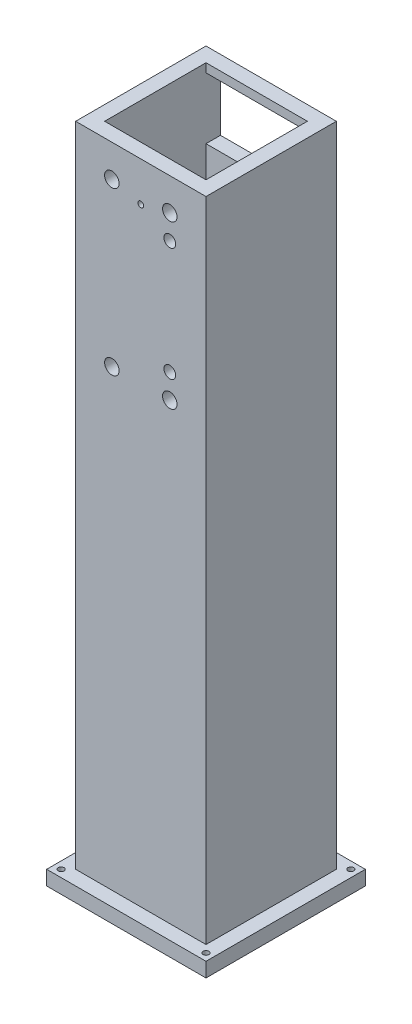
from build123d import *

# Parameters (mm, degrees)
CROQUIS1_W                 = 45
CROQUIS1_H                 = 45
SALIENTE_EXTRUIR1_DEPTH    = 300
CROQUIS4_W                 = 18
CROQUIS4_H                 = 34
CORTAR_EXTRUIR2_DEPTH      = 46
CROQUIS8_W                 = 35
CROQUIS8_H                 = 35
CORTAR_EXTRUIR3_DEPTH      = 301
CROQUIS9_W                 = 35
CROQUIS9_H                 = 21.174410022
CORTAR_EXTRUIR4_DEPTH      = 10
CROQUIS10_R                = 1
CORTAR_EXTRUIR5_DEPTH      = 10
CROQUIS11_W                = 45
CROQUIS11_H                = 26.387879272
CORTAR_EXTRUIR6_DEPTH      = 46
CROQUIS13_W                = 45
CROQUIS13_H                = 50
CORTAR_EXTRUIR7_DEPTH      = 23.5
CORTAR_EXTRUIR7_DEPTH_BACK = 23.5
CROQUIS14_W                = 55
CROQUIS14_H                = 55
SALIENTE_EXTRUIR2_DEPTH    = 5
CROQUIS16_R                = 1
CORTAR_EXTRUIR8_DEPTH      = 1
CORTAR_EXTRUIR8_DEPTH_BACK = 229.612120728
CROQUIS17_R                = 2.5
CROQUIS17_R_2              = 2.03
CORTAR_EXTRUIR9_DEPTH      = 6
CORTAR_EXTRUIR9_DEPTH_BACK = 51


with BuildPart() as part:
    # Croquis1 → Saliente-Extruir1 (new body)
    with BuildSketch(Plane(origin=(0, 0, 0), x_dir=(1, 0, 0), z_dir=(0, 1, 0))):
        Rectangle(CROQUIS1_W, CROQUIS1_H)
    extrude(amount=SALIENTE_EXTRUIR1_DEPTH)

    # Croquis4 → Cortar-Extruir2 (cut, through all)
    with BuildSketch(Plane.ZY.offset(22.5)):
        with Locations((13.5, 17)):
            Rectangle(CROQUIS4_W, CROQUIS4_H)
    extrude(amount=-CORTAR_EXTRUIR2_DEPTH, mode=Mode.SUBTRACT)

    # Croquis8 → Cortar-Extruir3 (cut, through all)
    with BuildSketch(Plane(origin=(0, 300, 0), x_dir=(1, 0, 0), z_dir=(0, 1, 0))):
        Rectangle(CROQUIS8_W, CROQUIS8_H)
    extrude(amount=-CORTAR_EXTRUIR3_DEPTH, mode=Mode.SUBTRACT)

    # Croquis9 → Cortar-Extruir4 (cut)
    with BuildSketch(Plane(origin=(0, 0, -22.5), x_dir=(-1, 0, 0), z_dir=(0, 0, -1))):
        with Locations((0, 260)):
            Rectangle(CROQUIS9_W, CROQUIS9_H)
    extrude(amount=-CORTAR_EXTRUIR4_DEPTH, mode=Mode.SUBTRACT)

    # Croquis10 → Cortar-Extruir5 (cut)
    with BuildSketch(Plane.XY.offset(22.5)):
        with Locations((0, 260)):
            Circle(CROQUIS10_R)
    extrude(amount=-CORTAR_EXTRUIR5_DEPTH, mode=Mode.SUBTRACT)

    # Croquis11 → Cortar-Extruir6 (cut, through all)
    with BuildSketch(Plane.XY.offset(22.5)):
        with Locations((0, 286.806060364)):
            Rectangle(CROQUIS11_W, CROQUIS11_H)
    extrude(amount=-CORTAR_EXTRUIR6_DEPTH, mode=Mode.SUBTRACT)

    # Croquis13 → Cortar-Extruir7 (cut, two sides)
    with BuildSketch(Plane(origin=(0, 0, 0), x_dir=(0, 0, -1), z_dir=(1, 0, 0))) as cortar_extruir7_sk:
        with Locations((0, 25)):
            Rectangle(CROQUIS13_W, CROQUIS13_H)
    extrude(amount=CORTAR_EXTRUIR7_DEPTH, mode=Mode.SUBTRACT)
    extrude(cortar_extruir7_sk.sketch, amount=-CORTAR_EXTRUIR7_DEPTH_BACK, mode=Mode.SUBTRACT)

    # Croquis14 → Saliente-Extruir2 (add)
    with BuildSketch(Plane.XZ.offset(-50)):
        Rectangle(CROQUIS14_W, CROQUIS14_H)
    extrude(amount=SALIENTE_EXTRUIR2_DEPTH)

    # Croquis16 → Cortar-Extruir8 (cut, two sides)
    with BuildSketch(Plane.XZ.offset(-45)) as cortar_extruir8_sk:
        with Locations((25, 25)):
            Circle(CROQUIS16_R)
        with Locations((-25, 25)):
            Circle(CROQUIS16_R)
        with Locations((-25, -25)):
            Circle(CROQUIS16_R)
        with Locations((25, -25)):
            Circle(CROQUIS16_R)
    extrude(amount=CORTAR_EXTRUIR8_DEPTH, mode=Mode.SUBTRACT)
    extrude(cortar_extruir8_sk.sketch, amount=-CORTAR_EXTRUIR8_DEPTH_BACK, mode=Mode.SUBTRACT)

    # Croquis17 → Cortar-Extruir9 (cut, two sides)
    with BuildSketch(Plane.XY.offset(22.5)) as cortar_extruir9_sk:
        with Locations((-10, 262.50260741)):
            Circle(CROQUIS17_R)
        with Locations((-10, 206.50260741)):
            Circle(CROQUIS17_R)
        with Locations((10, 262.50260741)):
            Circle(CROQUIS17_R)
        with Locations((10, 206.50260741)):
            Circle(CROQUIS17_R)
        with Locations((10, 254.10260741)):
            Circle(CROQUIS17_R_2)
        with Locations((10, 214.90260741)):
            Circle(CROQUIS17_R_2)
    extrude(amount=CORTAR_EXTRUIR9_DEPTH, mode=Mode.SUBTRACT)
    extrude(cortar_extruir9_sk.sketch, amount=-CORTAR_EXTRUIR9_DEPTH_BACK, mode=Mode.SUBTRACT)


solid = part.part
